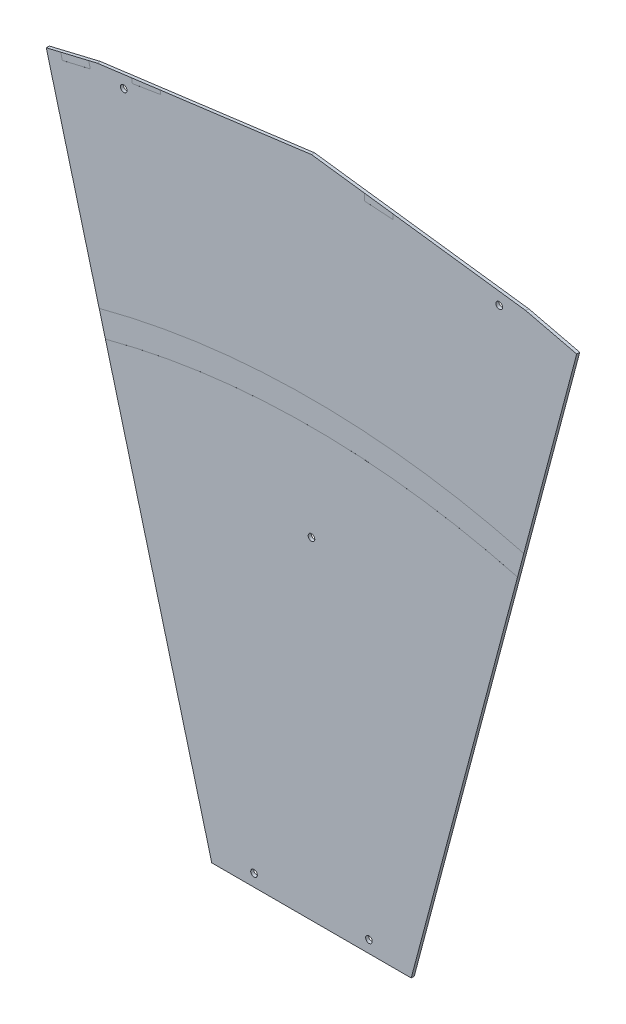
from build123d import *

# Parameters (mm, degrees)
EXTRUDE1_DEPTH     = 1.5875
EXTRUDE3_DEPTH     = 2.5875
SKETCH3_R          = 1.7272
EXTRUDE2_DEPTH     = 2.5875
CUT_EXTRUDE1_DEPTH = 0.005


with BuildPart() as part:
    # Sketch1 → Extrude1 (new body)
    with BuildSketch(Plane(origin=(0, 0, 0), x_dir=(-1, 0, 0), z_dir=(0, 0, -1))):
        Polygon((-139.214433641, 524.126541463), (-52.060002376, 196), (52.060002376, 196), (139.214433641, 524.126541463), (0, 542.3), align=None)
    extrude(amount=-EXTRUDE1_DEPTH)

    # Sketch5 → Extrude3 (cut, through all)
    with BuildSketch(Plane.XY.offset(1.5875)):
        Polygon((-138.475953663, 521.346248167), (-111.862580021, 527.697132275), (-139.214433641, 524.126541463), align=None)
        Polygon((139.214433641, 524.126541463), (138.475953663, 521.346248167), (111.862580021, 527.697132275), align=None)
    extrude(amount=-EXTRUDE3_DEPTH, mode=Mode.SUBTRACT)

    # Sketch3 → Extrude2 (cut, through all)
    with BuildSketch(Plane.XY.offset(1.5875)):
        with Locations((-98.040924265, 523.097573518)):
            Circle(SKETCH3_R)
        with Locations((-30, 202.35)):
            Circle(SKETCH3_R)
        with Locations(Location((30, 202.35, 0), (0, 0, 180))):  # turned: the seam where the file's is
            Circle(SKETCH3_R)
        with Locations(Location((98.040924265, 523.097573518, 0), (0, 0, 180))):  # turned: the seam where the file's is
            Circle(SKETCH3_R)
        with Locations((0, 369.15)):
            Circle(SKETCH3_R)
    extrude(amount=-EXTRUDE2_DEPTH, mode=Mode.SUBTRACT)

    # Sketch4 → Cut-Extrude1 (cut)
    with BuildSketch(Plane.XY.offset(1.5875)):
        with BuildLine():
            Line((110.847856253, 417.329597278), (107.587625187, 405.055197358))
            ThreePointArc((107.587625187, 405.055197358), (0, 419.1), (-107.587625187, 405.055197358))
            Line((-107.587625187, 405.055197358), (-110.847856253, 417.329597278))
            ThreePointArc((-110.847856253, 417.329597278), (0, 431.8), (110.847856253, 417.329597278))
        make_face()
        Polygon((-93.921186267, 530.039254187), (-93.5283394, 527.627083961), (-78.723393901, 530.038222445), (-79.039941137, 531.981895365), align=None)
        Polygon((27.790346618, 538.672167032), (27.559054717, 535.14333454), (42.526938566, 534.162287602), (42.695003931, 536.726469559), align=None)
        Polygon((-131.361910987, 525.151632692), (-130.105913895, 519.817603751), (-115.505225018, 523.255609615), (-116.411244397, 527.10333635), align=None)
    extrude(amount=-CUT_EXTRUDE1_DEPTH, mode=Mode.SUBTRACT)


solid = part.part
